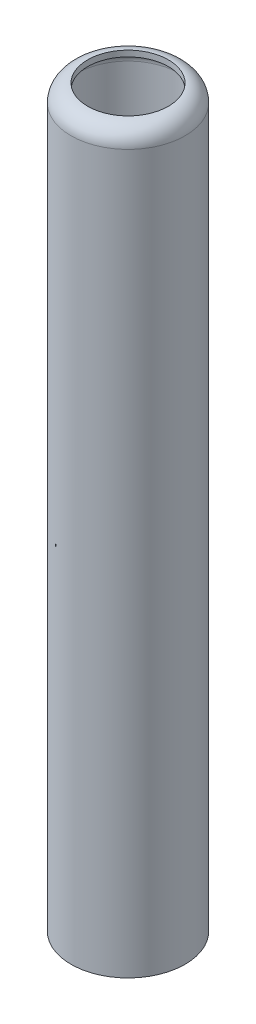
from build123d import *

# Parameters (mm, degrees)
SKETCH1_R           = 14.5
BASE_DEPTH          = 186.69
TOP_FILLET_R        = 4.365625
CASING_WALLS_T      = -1.5
SKETCH2_R           = 10.25
TOP_HOLE_DEPTH      = 188.812821995
TOP_HOLE_DEPTH_BACK = 188.812821995


with BuildPart() as part:
    # Sketch1 → base (new body)
    with BuildSketch(Plane(origin=(0, 0, 0), x_dir=(1, 0, 0), z_dir=(0, 1, 0))):
        with Locations(Location((0, 0, 0), (0, 0, 90))):
            Circle(SKETCH1_R)
    extrude(amount=BASE_DEPTH)

    # top-fillet
    top_fillet_edges = [part.edges().sort_by_distance(p)[0] for p in [
        (0, 186.69, 14.5),
    ]]
    fillet(top_fillet_edges, radius=TOP_FILLET_R)

    # casing-walls
    casing_walls_openings = [part.faces().sort_by_distance(p)[0] for p in [
        (0, 0, 0),
    ]]
    offset(amount=CASING_WALLS_T, openings=casing_walls_openings, kind=Kind.INTERSECTION)

    # Sketch2 → top-hole (cut, two sides)
    with BuildSketch(Plane(origin=(0, 0, 0), x_dir=(1, 0, 0), z_dir=(0, 1, 0))) as top_hole_sk:
        with Locations(Location((0, 0, 0), (0, 0, 270))):
            Circle(SKETCH2_R)
    extrude(amount=TOP_HOLE_DEPTH, mode=Mode.SUBTRACT)
    extrude(top_hole_sk.sketch, amount=-TOP_HOLE_DEPTH_BACK, mode=Mode.SUBTRACT)


solid = part.part
